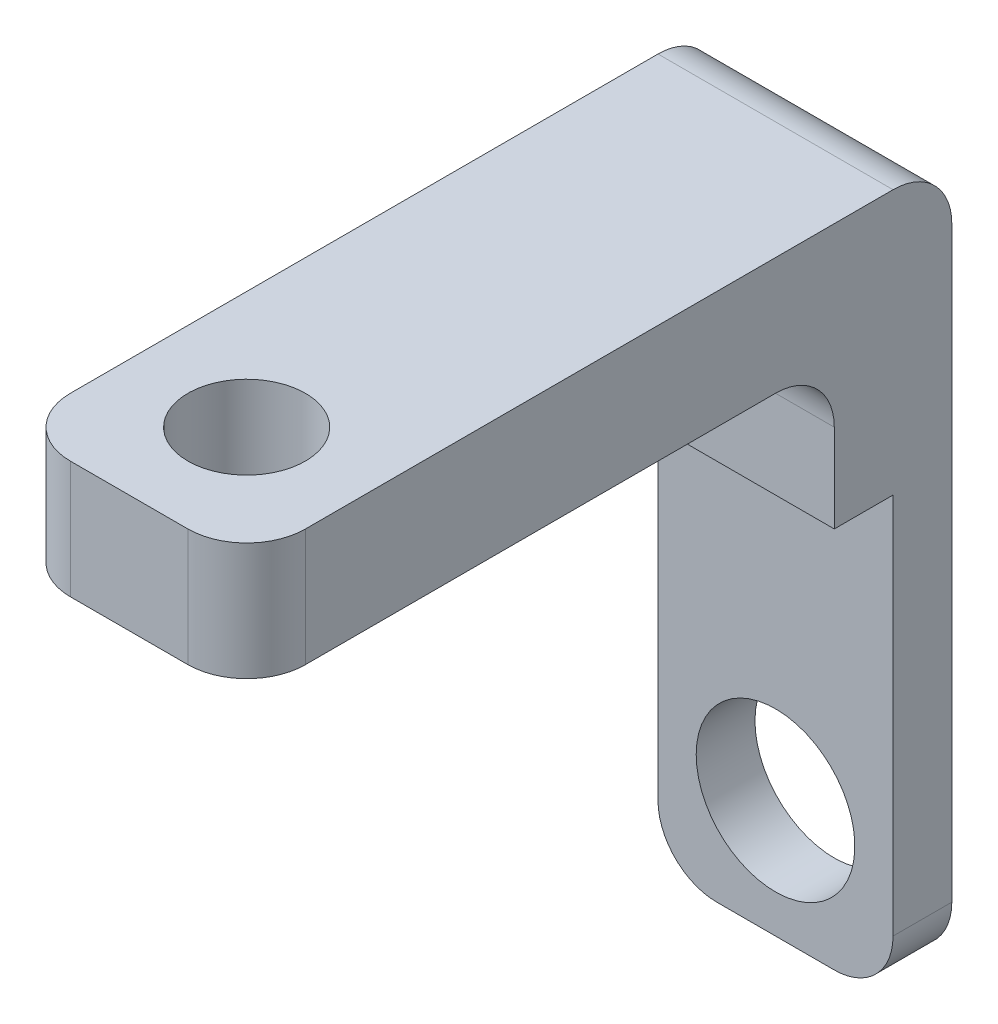
from build123d import *

# Parameters (mm, degrees)
SKETCH1_W           = 40
SKETCH1_H           = 120
BOSS_EXTRUDE1_DEPTH = 20
SKETCH3_W           = 40
SKETCH3_H           = 20
BOSS_EXTRUDE3_DEPTH = 100
SKETCH4_W           = 40
SKETCH4_H           = 75
CUT_EXTRUDE1_DEPTH  = 10
FILLET1_R           = 10
CUT_EXTRUDE2_REACH  = 122
SKETCH5_R           = 13.5
CUT_EXTRUDE3_REACH  = 122
SKETCH6_R           = 10
FILLET2_R           = 10


with BuildPart() as part:
    # Sketch1 → Boss-Extrude1 (new body)
    with BuildSketch(Plane(origin=(0, 0, 0), x_dir=(1, 0, 0), z_dir=(0, 1, 0))):
        Rectangle(SKETCH1_W, SKETCH1_H)
    extrude(amount=BOSS_EXTRUDE1_DEPTH)

    # Sketch3 → Boss-Extrude3 (add)
    with BuildSketch(Plane.XZ):
        with Locations((0, -50)):
            Rectangle(SKETCH3_W, SKETCH3_H)
    extrude(amount=BOSS_EXTRUDE3_DEPTH)

    # Sketch4 → Cut-Extrude1 (cut)
    with BuildSketch(Plane.XY.offset(-40)):
        with Locations((0, -62.5)):
            Rectangle(SKETCH4_W, SKETCH4_H)
    extrude(amount=-CUT_EXTRUDE1_DEPTH, mode=Mode.SUBTRACT)

    # Fillet1
    fillet1_edges = [part.edges().sort_by_distance(p)[0] for p in [
        (20, 10, 60),
        (-20, 10, 60),
        (20, -100, -55),
        (-20, -100, -55),
        (0, 20, -60),
    ]]
    fillet(fillet1_edges, radius=FILLET1_R)

    # Sketch5 → Cut-Extrude2 (cut, up to next)
    with BuildSketch(Plane(origin=(0, 0, -60), x_dir=(-1, 0, 0), z_dir=(0, 0, -1)), mode=Mode.PRIVATE) as cut_extrude2_sk1:
        with Locations((0, -80)):
            Circle(SKETCH5_R)
    cut_extrude2_tool1 = extrude(cut_extrude2_sk1.sketch, amount=-CUT_EXTRUDE2_REACH, mode=Mode.PRIVATE) & part.part
    add(cut_extrude2_tool1.solids().sort_by_distance((0, -80, -60))[0], mode=Mode.SUBTRACT)

    # Sketch6 → Cut-Extrude3 (cut, up to next)
    with BuildSketch(Plane(origin=(0, 20, 0), x_dir=(1, 0, 0), z_dir=(0, 1, 0)), mode=Mode.PRIVATE) as cut_extrude3_sk1:
        with Locations((0, -40)):
            Circle(SKETCH6_R)
    cut_extrude3_tool1 = extrude(cut_extrude3_sk1.sketch, amount=-CUT_EXTRUDE3_REACH, mode=Mode.PRIVATE) & part.part
    add(cut_extrude3_tool1.solids().sort_by_distance((0, 20, 40))[0], mode=Mode.SUBTRACT)

    # Fillet2
    fillet2_edges = [part.edges().sort_by_distance(p)[0] for p in [
        (0, 0, -40),
    ]]
    fillet(fillet2_edges, radius=FILLET2_R)


solid = part.part
